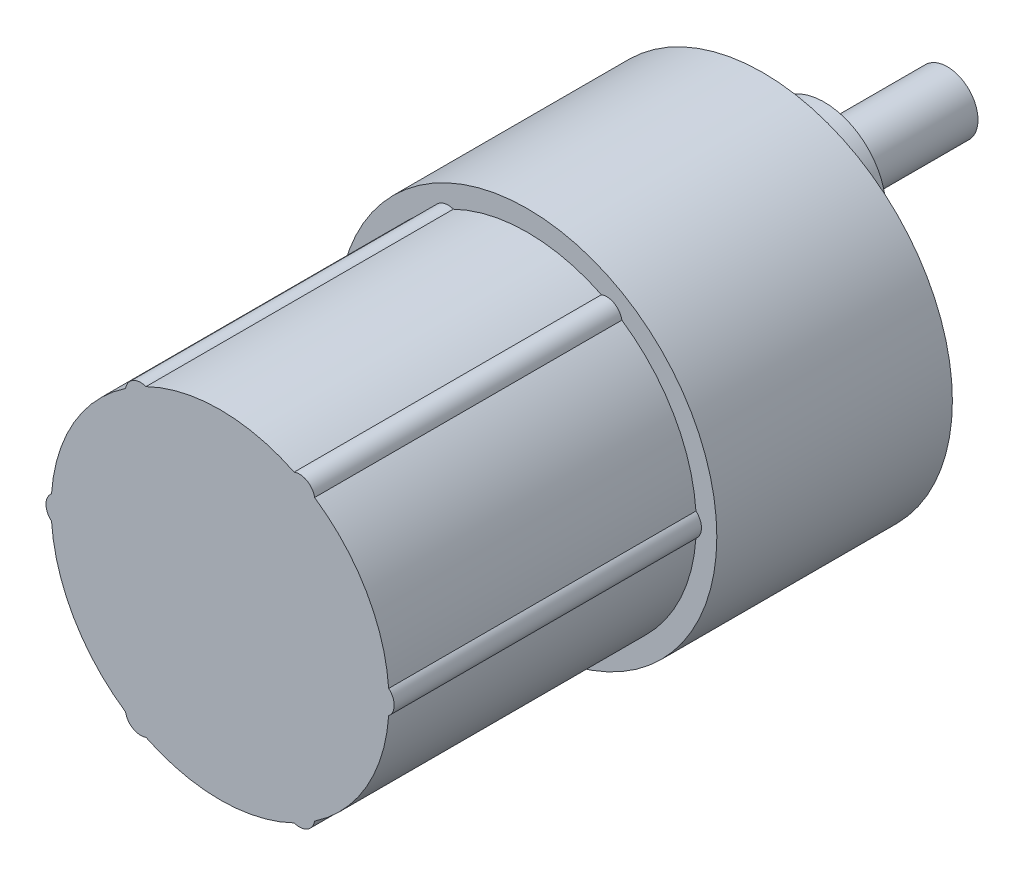
from build123d import *

# Parameters (mm, degrees)
SKETCH_1_R          = 18.5
SKETCH_1_R_2        = 1.5
EXTRUDE_1_DEPTH     = 23
SKETCH_1_3_R        = 6
SKETCH_1_3_R_2      = 3
EXTRUDE_2_DEPTH     = 6
SKETCH_1_4_R        = 3
EXTRUDE_3_DEPTH     = 18
EXTRUDE_5_DEPTH     = 53
SKETCH_1_6_R        = 1.5
CUT_EXTRUDE_3_DEPTH = 10


with BuildPart() as part:
    # 草图1 → 凸台-拉伸1 (new body)
    with BuildSketch(Plane.XY):
        Circle(SKETCH_1_R)
        with Locations((7.75, 13.423393759)):
            Circle(SKETCH_1_R_2, mode=Mode.SUBTRACT)
        with Locations((-7.75, 13.423393759)):
            Circle(SKETCH_1_R_2, mode=Mode.SUBTRACT)
        with Locations((-15.5, 0)):
            Circle(SKETCH_1_R_2, mode=Mode.SUBTRACT)
        with Locations((-7.75, -13.423393759)):
            Circle(SKETCH_1_R_2, mode=Mode.SUBTRACT)
        with Locations((7.75, -13.423393759)):
            Circle(SKETCH_1_R_2, mode=Mode.SUBTRACT)
        with Locations((15.5, 0)):
            Circle(SKETCH_1_R_2, mode=Mode.SUBTRACT)
    extrude(amount=EXTRUDE_1_DEPTH)

    # 草图1<3> → 凸台-拉伸2 (add)
    with BuildSketch(Plane.XY):
        with Locations((0, 7)):
            Circle(SKETCH_1_3_R)
        with Locations((0, 7)):
            Circle(SKETCH_1_3_R_2, mode=Mode.SUBTRACT)
    extrude(amount=-EXTRUDE_2_DEPTH)

    # 草图1<4> → 凸台-拉伸3 (add)
    with BuildSketch(Plane.XY):
        with Locations((0, 7)):
            Circle(SKETCH_1_4_R)
    extrude(amount=-EXTRUDE_3_DEPTH)

    # 草图1<5> → 凸台-拉伸5 (add)
    with BuildSketch(Plane.XY):
        with BuildLine():
            ThreePointArc((16.459677419, -1.152830972), (17, 0), (16.459677419, 1.152830972))
            ThreePointArc((16.459677419, 1.152830972), (14.289419162, 8.25), (9.228219618, 13.678083297))
            ThreePointArc((9.228219618, 13.678083297), (8.5, 14.722431864), (7.231457801, 14.830914269))
            ThreePointArc((7.231457801, 14.830914269), (0, 16.5), (-7.231457801, 14.830914269))
            ThreePointArc((-7.231457801, 14.830914269), (-8.5, 14.722431864), (-9.228219618, 13.678083297))
            ThreePointArc((-9.228219618, 13.678083297), (-14.289419162, 8.25), (-16.459677419, 1.152830972))
            ThreePointArc((-16.459677419, 1.152830972), (-17, 0), (-16.459677419, -1.152830972))
            ThreePointArc((-16.459677419, -1.152830972), (-14.289419162, -8.25), (-9.228219618, -13.678083297))
            ThreePointArc((-9.228219618, -13.678083297), (-8.5, -14.722431864), (-7.231457801, -14.830914269))
            ThreePointArc((-7.231457801, -14.830914269), (0, -16.5), (7.231457801, -14.830914269))
            ThreePointArc((7.231457801, -14.830914269), (8.5, -14.722431864), (9.228219618, -13.678083297))
            ThreePointArc((9.228219618, -13.678083297), (14.289419162, -8.25), (16.459677419, -1.152830972))
        make_face()
    extrude(amount=EXTRUDE_5_DEPTH)

    # 草图1<6> → 切除-拉伸3 (cut)
    with BuildSketch(Plane.XY):
        with Locations((15.5, 0)):
            Circle(SKETCH_1_6_R)
        with Locations((7.75, 13.423393759)):
            Circle(SKETCH_1_6_R)
        with Locations((7.75, -13.423393759)):
            Circle(SKETCH_1_6_R)
        with Locations((-7.75, 13.423393759)):
            Circle(SKETCH_1_6_R)
        with Locations((-7.75, -13.423393759)):
            Circle(SKETCH_1_6_R)
        with Locations((-15.5, 0)):
            Circle(SKETCH_1_6_R)
    extrude(amount=CUT_EXTRUDE_3_DEPTH, mode=Mode.SUBTRACT)


solid = part.part
